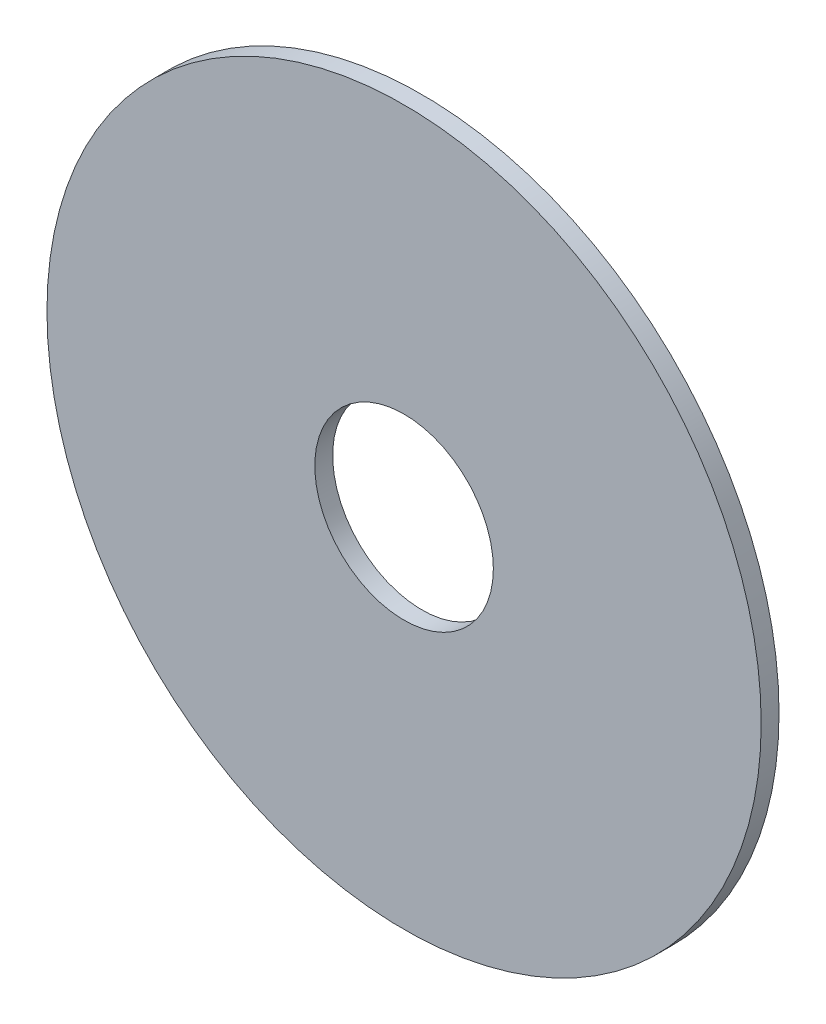
from build123d import *

# Parameters (mm, degrees)
SKETCH1_R           = 20
BOSS_EXTRUDE1_DEPTH = 1
SKETCH2_R           = 5
CUT_EXTRUDE1_DEPTH  = 4


with BuildPart() as part:
    # Sketch1 → Boss-Extrude1 (new body)
    with BuildSketch(Plane.XY):
        Circle(SKETCH1_R)
    extrude(amount=BOSS_EXTRUDE1_DEPTH)

    # Sketch2 → Cut-Extrude1 (cut)
    with BuildSketch(Plane.XY.offset(1)):
        Circle(SKETCH2_R)
    extrude(amount=-CUT_EXTRUDE1_DEPTH, mode=Mode.SUBTRACT)


solid = part.part
